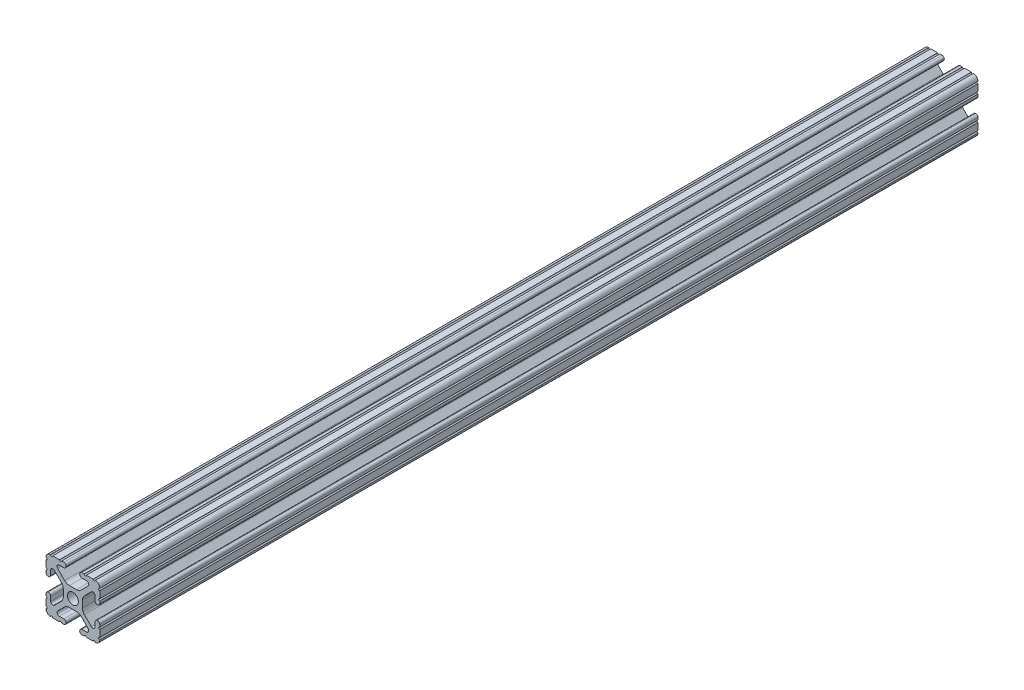
from build123d import *

# Parameters (mm, degrees)
SKETCH1_R           = 2.6035
BOSS_EXTRUDE1_DEPTH = 207.5


with BuildPart() as part:
    # Sketch1 → Boss-Extrude1 (new body, symmetric)
    with BuildSketch(Plane.XY):
        with BuildLine():
            Line((-7.179650497, -8.645192506), (-3.952270251, -5.423690499))
            ThreePointArc((-3.952270251, -5.423690499), (-2.922936451, -4.736929036), (-1.709253557, -4.4958))
            Line((-1.709253557, -4.4958), (1.709253557, -4.4958))
            ThreePointArc((1.709253557, -4.4958), (2.922936451, -4.736929036), (3.952270251, -5.423690499))
            Line((3.952270251, -5.423690499), (7.179650497, -8.645192506))
            ThreePointArc((7.179650497, -8.645192506), (7.41473083, -9.822813117), (6.416408329, -10.4902))
            Line((6.416408329, -10.4902), (4.287512407, -10.4902))
            ThreePointArc((4.287512407, -10.4902), (3.54574862, -10.79744862), (3.2385, -11.539212407))
            Line((3.2385, -11.539212407), (3.2385, -11.650987593))
            ThreePointArc((3.2385, -11.650987593), (3.54574862, -12.39275138), (4.287512407, -12.7))
            Line((4.287512407, -12.7), (5.317126718, -12.7))
            ThreePointArc((5.317126718, -12.7), (5.825126718, -12.192), (6.333126718, -12.7))
            Line((6.333126718, -12.7), (9.550443118, -12.7))
            ThreePointArc((9.550443118, -12.7), (10.058366869, -12.192000006), (10.566443095, -12.699847501))
            ThreePointArc((10.566443095, -12.699847501), (12.082537762, -12.08250727), (12.699846982, -10.566399977))
            ThreePointArc((12.699846982, -10.566399977), (12.192000006, -10.058323491), (12.7, -9.5504))
            Line((12.7, -9.5504), (12.7, -6.3330836))
            ThreePointArc((12.7, -6.3330836), (12.192, -5.8250836), (12.7, -5.3170836))
            Line((12.7, -5.3170836), (12.7, -4.287469289))
            ThreePointArc((12.7, -4.287469289), (12.39275138, -3.545705502), (11.650987593, -3.238456882))
            Line((11.650987593, -3.238456882), (11.539212407, -3.238456882))
            ThreePointArc((11.539212407, -3.238456882), (10.79744862, -3.545705502), (10.4902, -4.287469289))
            Line((10.4902, -4.287469289), (10.4902, -6.402089023))
            ThreePointArc((10.4902, -6.402089023), (9.856505071, -7.351067942), (8.737131347, -7.129408934))
            Line((8.737131347, -7.129408934), (5.441005833, -3.840816462))
            ThreePointArc((5.441005833, -3.840816462), (4.750877967, -2.809883091), (4.5085, -1.593185507))
            Line((4.5085, -1.593185507), (4.5085, 1.593185507))
            ThreePointArc((4.5085, 1.593185507), (4.750877967, 2.809883091), (5.441005833, 3.840816462))
            Line((5.441005833, 3.840816462), (8.737131347, 7.129408934))
            ThreePointArc((8.737131347, 7.129408934), (9.856505071, 7.351067942), (10.4902, 6.402089023))
            Line((10.4902, 6.402089023), (10.4902, 4.287469289))
            ThreePointArc((10.4902, 4.287469289), (10.79744862, 3.545705502), (11.539212407, 3.238456882))
            Line((11.539212407, 3.238456882), (11.650987593, 3.238456882))
            ThreePointArc((11.650987593, 3.238456882), (12.39275138, 3.545705502), (12.7, 4.287469289))
            Line((12.7, 4.287469289), (12.7, 5.3170836))
            ThreePointArc((12.7, 5.3170836), (12.192, 5.8250836), (12.7, 6.3330836))
            Line((12.7, 6.3330836), (12.7, 9.5504))
            ThreePointArc((12.7, 9.5504), (12.192000006, 10.058323491), (12.699846982, 10.566399977))
            ThreePointArc((12.699846982, 10.566399977), (12.082537762, 12.08250727), (10.566443095, 12.699847501))
            ThreePointArc((10.566443095, 12.699847501), (10.058366869, 12.192000006), (9.550443118, 12.7))
            Line((9.550443118, 12.7), (6.333126718, 12.7))
            ThreePointArc((6.333126718, 12.7), (5.825126718, 12.192), (5.317126718, 12.7))
            Line((5.317126718, 12.7), (4.287512407, 12.7))
            ThreePointArc((4.287512407, 12.7), (3.54574862, 12.39275138), (3.2385, 11.650987593))
            Line((3.2385, 11.650987593), (3.2385, 11.539212407))
            ThreePointArc((3.2385, 11.539212407), (3.54574862, 10.79744862), (4.287512407, 10.4902))
            Line((4.287512407, 10.4902), (6.476788598, 10.4902))
            ThreePointArc((6.476788598, 10.4902), (7.432222385, 9.85140422), (7.207036008, 8.724370562))
            Line((7.207036008, 8.724370562), (3.898272566, 5.423169045))
            ThreePointArc((3.898272566, 5.423169045), (2.869120213, 4.736787962), (1.655778399, 4.4958))
            Line((1.655778399, 4.4958), (-1.655778399, 4.4958))
            ThreePointArc((-1.655778399, 4.4958), (-2.869120213, 4.736787962), (-3.898272566, 5.423169045))
            Line((-3.898272566, 5.423169045), (-7.207036008, 8.724370562))
            ThreePointArc((-7.207036008, 8.724370562), (-7.432222385, 9.85140422), (-6.476788598, 10.4902))
            Line((-6.476788598, 10.4902), (-4.287512407, 10.4902))
            ThreePointArc((-4.287512407, 10.4902), (-3.54574862, 10.79744862), (-3.2385, 11.539212407))
            Line((-3.2385, 11.539212407), (-3.2385, 11.650987593))
            ThreePointArc((-3.2385, 11.650987593), (-3.54574862, 12.39275138), (-4.287512407, 12.7))
            Line((-4.287512407, 12.7), (-5.317126718, 12.7))
            ThreePointArc((-5.317126718, 12.7), (-5.825126718, 12.192), (-6.333126718, 12.7))
            Line((-6.333126718, 12.7), (-9.550443118, 12.7))
            ThreePointArc((-9.550443118, 12.7), (-10.058366869, 12.192000006), (-10.566443095, 12.699847501))
            ThreePointArc((-10.566443095, 12.699847501), (-12.082537762, 12.08250727), (-12.699846982, 10.566399977))
            ThreePointArc((-12.699846982, 10.566399977), (-12.192000006, 10.058323491), (-12.7, 9.5504))
            Line((-12.7, 9.5504), (-12.7, 6.3330836))
            ThreePointArc((-12.7, 6.3330836), (-12.192, 5.8250836), (-12.7, 5.3170836))
            Line((-12.7, 5.3170836), (-12.7, 4.287469289))
            ThreePointArc((-12.7, 4.287469289), (-12.39275138, 3.545705502), (-11.650987593, 3.238456882))
            Line((-11.650987593, 3.238456882), (-11.539212407, 3.238456882))
            ThreePointArc((-11.539212407, 3.238456882), (-10.79744862, 3.545705502), (-10.4902, 4.287469289))
            Line((-10.4902, 4.287469289), (-10.4902, 6.402089023))
            ThreePointArc((-10.4902, 6.402089023), (-9.856505071, 7.351067942), (-8.737131347, 7.129408934))
            Line((-8.737131347, 7.129408934), (-5.441005833, 3.840816462))
            ThreePointArc((-5.441005833, 3.840816462), (-4.750877967, 2.809883091), (-4.5085, 1.593185507))
            Line((-4.5085, 1.593185507), (-4.5085, -1.593185507))
            ThreePointArc((-4.5085, -1.593185507), (-4.750877967, -2.809883091), (-5.441005833, -3.840816462))
            Line((-5.441005833, -3.840816462), (-8.737131347, -7.129408934))
            ThreePointArc((-8.737131347, -7.129408934), (-9.856505071, -7.351067942), (-10.4902, -6.402089023))
            Line((-10.4902, -6.402089023), (-10.4902, -4.287469289))
            ThreePointArc((-10.4902, -4.287469289), (-10.79744862, -3.545705502), (-11.539212407, -3.238456882))
            Line((-11.539212407, -3.238456882), (-11.650987593, -3.238456882))
            ThreePointArc((-11.650987593, -3.238456882), (-12.39275138, -3.545705502), (-12.7, -4.287469289))
            Line((-12.7, -4.287469289), (-12.7, -5.3170836))
            ThreePointArc((-12.7, -5.3170836), (-12.192, -5.8250836), (-12.7, -6.3330836))
            Line((-12.7, -6.3330836), (-12.7, -9.5504))
            ThreePointArc((-12.7, -9.5504), (-12.192000006, -10.058323491), (-12.699846982, -10.566399977))
            ThreePointArc((-12.699846982, -10.566399977), (-12.082537762, -12.08250727), (-10.566443095, -12.699847501))
            ThreePointArc((-10.566443095, -12.699847501), (-10.058366869, -12.192000006), (-9.550443118, -12.7))
            Line((-9.550443118, -12.7), (-6.333126718, -12.7))
            ThreePointArc((-6.333126718, -12.7), (-5.825126718, -12.192), (-5.317126718, -12.7))
            Line((-5.317126718, -12.7), (-4.287512407, -12.7))
            ThreePointArc((-4.287512407, -12.7), (-3.54574862, -12.39275138), (-3.2385, -11.650987593))
            Line((-3.2385, -11.650987593), (-3.2385, -11.539212407))
            ThreePointArc((-3.2385, -11.539212407), (-3.54574862, -10.79744862), (-4.287512407, -10.4902))
            Line((-4.287512407, -10.4902), (-6.416408329, -10.4902))
            ThreePointArc((-6.416408329, -10.4902), (-7.41473083, -9.822813117), (-7.179650497, -8.645192506))
        make_face()
        Circle(SKETCH1_R, mode=Mode.SUBTRACT)
    extrude(amount=BOSS_EXTRUDE1_DEPTH, both=True)


solid = part.part
